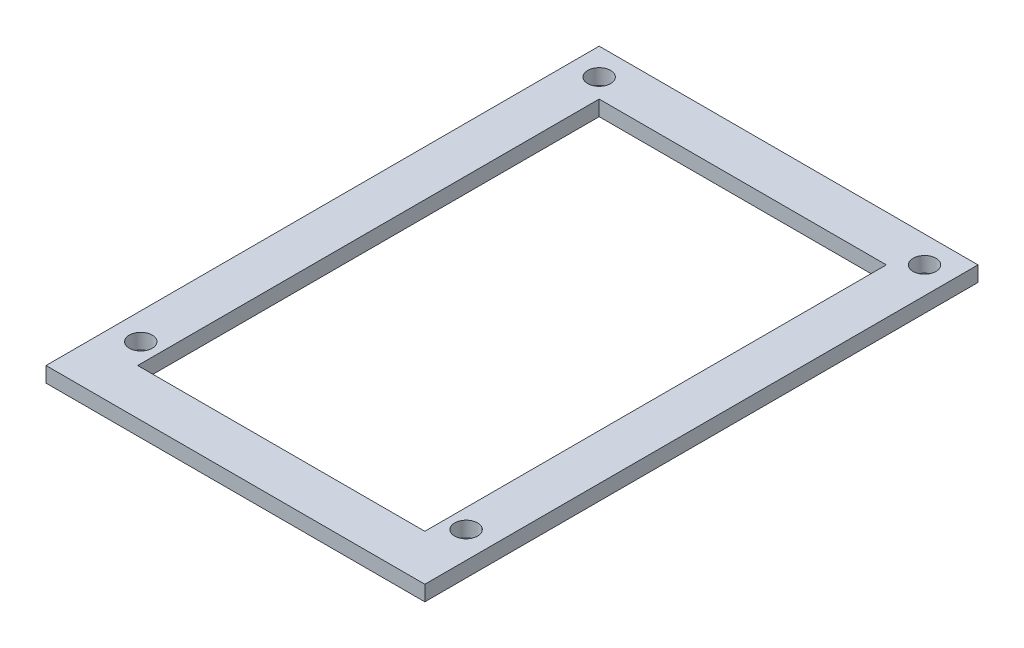
from build123d import *

# Parameters (mm, degrees)
SKETCH1_R           = 1.190625
BOSS_EXTRUDE1_DEPTH = 1.5875


with BuildPart() as part:
    # Sketch1 → Boss-Extrude1 (new body)
    with BuildSketch(Plane(origin=(0, 0, 0), x_dir=(1, 0, 0), z_dir=(0, 1, 0))):
        Polygon((0, 54.692295537), (0, 7.067295537), (0, 0), (39.359085702, 0), (39.359085702, 7.067295537), (39.359085702, 54.692295537), (39.359085702, 57.470420537), (0, 57.470420537), align=None)
        with Locations((2.778125, 54.692295537)):
            Circle(SKETCH1_R, mode=Mode.SUBTRACT)
        with Locations((36.580960702, 7.067295537)):
            Circle(SKETCH1_R, mode=Mode.SUBTRACT)
        with Locations((2.778125, 7.067295537)):
            Circle(SKETCH1_R, mode=Mode.SUBTRACT)
        with Locations((36.580960702, 54.692295537)):
            Circle(SKETCH1_R, mode=Mode.SUBTRACT)
        Polygon((4.7625, 52.707920537), (4.7625, 7.067295537), (4.7625, 4.7625), (34.596585702, 4.7625), (34.596585702, 7.067295537), (34.596585702, 52.707920537), align=None, mode=Mode.SUBTRACT)
    extrude(amount=BOSS_EXTRUDE1_DEPTH)


solid = part.part
